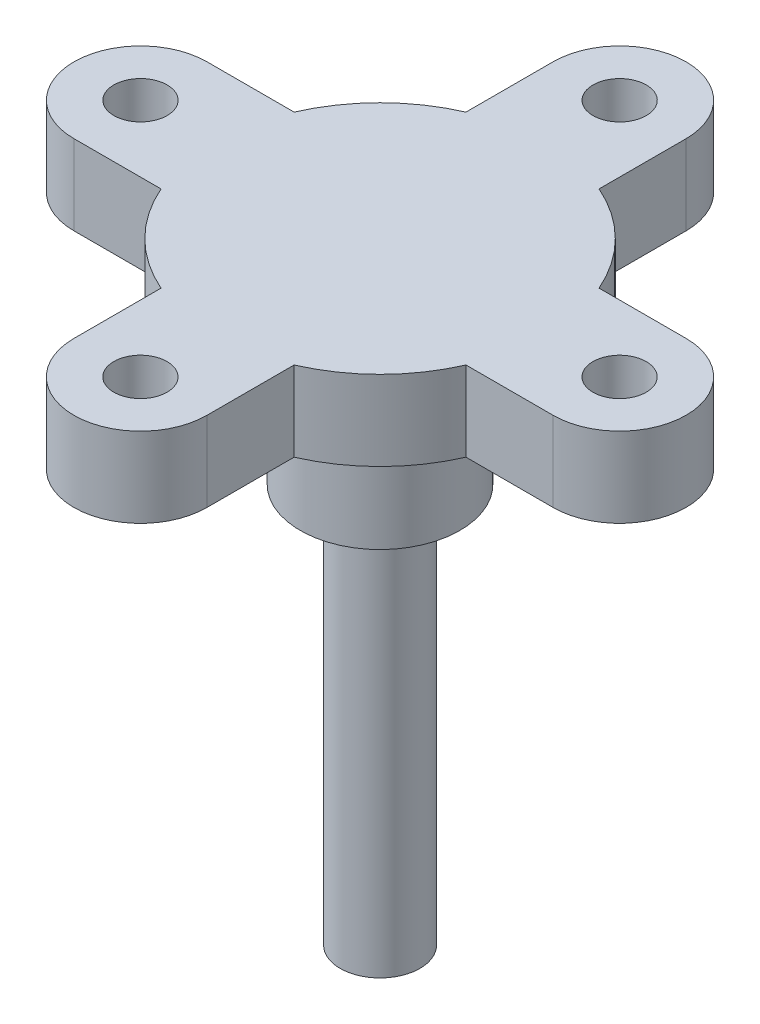
from build123d import *

# Parameters (mm, degrees)
SKETCH2_R           = 10
BOSS_EXTRUDE1_DEPTH = 30
SKETCH3_R           = 30
BOSS_EXTRUDE2_DEPTH = 50
SKETCH3_3_R         = 15
BOSS_EXTRUDE3_DEPTH = 200
FILLET1_R           = 10
SCALE1_SCALE        = 0.3


with BuildPart() as part:
    # Sketch2 → Boss-Extrude1 (new body)
    with BuildSketch(Plane.XZ.offset(245.071627094)):
        with BuildLine():
            Line((57.282196187, 25), (90, 25))
            ThreePointArc((90, 25), (115, 0), (90, -25))
            Line((90, -25), (57.282196187, -25))
            ThreePointArc((57.282196187, -25), (44.194173824, -44.194173824), (25, -57.282196187))
            Line((25, -57.282196187), (25, -90))
            ThreePointArc((25, -90), (0, -115), (-25, -90))
            Line((-25, -90), (-25, -57.282196187))
            ThreePointArc((-25, -57.282196187), (-44.194173824, -44.194173824), (-57.282196187, -25))
            Line((-57.282196187, -25), (-90, -25))
            ThreePointArc((-90, -25), (-115, 0), (-90, 25))
            Line((-90, 25), (-57.282196187, 25))
            ThreePointArc((-57.282196187, 25), (-44.194173824, 44.194173824), (-25, 57.282196187))
            Line((-25, 57.282196187), (-25, 90))
            ThreePointArc((-25, 90), (0, 115.02832634), (25, 90))
            Line((25, 90), (25, 57.282196187))
            ThreePointArc((25, 57.282196187), (44.194173824, 44.194173824), (57.282196187, 25))
        make_face()
        with Locations((0, 90.028310311)):
            Circle(SKETCH2_R, mode=Mode.SUBTRACT)
        with Locations((90.028310311, 0.028310311)):
            Circle(SKETCH2_R, mode=Mode.SUBTRACT)
        with Locations((0.028310311, -90)):
            Circle(SKETCH2_R, mode=Mode.SUBTRACT)
        with Locations((-90, 0)):
            Circle(SKETCH2_R, mode=Mode.SUBTRACT)
    extrude(amount=BOSS_EXTRUDE1_DEPTH)

    # Sketch3 → Boss-Extrude2 (add)
    with BuildSketch(Plane.XZ.offset(275.071627094)):
        Circle(SKETCH3_R)
    extrude(amount=BOSS_EXTRUDE2_DEPTH)

    # Sketch3_3 → Boss-Extrude3 (add)
    with BuildSketch(Plane.XZ.offset(275.071627094)):
        Circle(SKETCH3_3_R)
    extrude(amount=BOSS_EXTRUDE3_DEPTH)

    # Fillet1
    fillet1_edges = [part.edges().sort_by_distance(p)[0] for p in [
        (-15, -325.071627094, 0),
    ]]
    fillet(fillet1_edges, radius=FILLET1_R)


with BuildPart() as part_1:
    # Scale1: scaled about (-0.000611067, -283.723455746, 0.004725438)
    add(part.part.scale(SCALE1_SCALE).moved(Location((-0.000427747, -198.606419022, 0.003307807))))


solid = part_1.part
